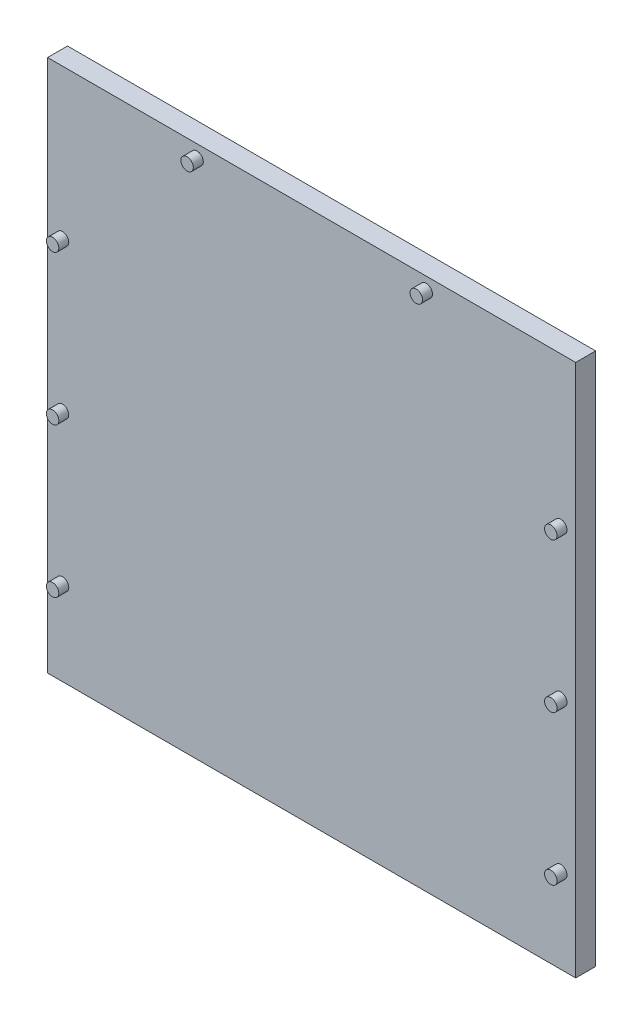
from build123d import *

# Parameters (mm, degrees)
SKETCH1_W  = 53
SKETCH1_H  = 53.5
BODY_DEPTH = 2
SKETCH2_R  = 0.625
PINS_DEPTH = 1


with BuildPart() as part:
    # Sketch1 → body (new body)
    with BuildSketch(Plane.XY):
        Rectangle(SKETCH1_W, SKETCH1_H)
    extrude(amount=BODY_DEPTH)

    # Sketch2 → pins (add)
    with BuildSketch(Plane.XY.offset(2)):
        with Locations((-11.5, 25.5)):
            Circle(SKETCH2_R)
        with Locations((11.5, 25.5)):
            Circle(SKETCH2_R)
        with Locations((-25, 11.75)):
            Circle(SKETCH2_R)
        with Locations((-25, -3.25)):
            Circle(SKETCH2_R)
        with Locations((-25, -18.25)):
            Circle(SKETCH2_R)
        with Locations((25, 11.75)):
            Circle(SKETCH2_R)
        with Locations((25, -3.25)):
            Circle(SKETCH2_R)
        with Locations((25, -18.25)):
            Circle(SKETCH2_R)
    extrude(amount=PINS_DEPTH)


solid = part.part
